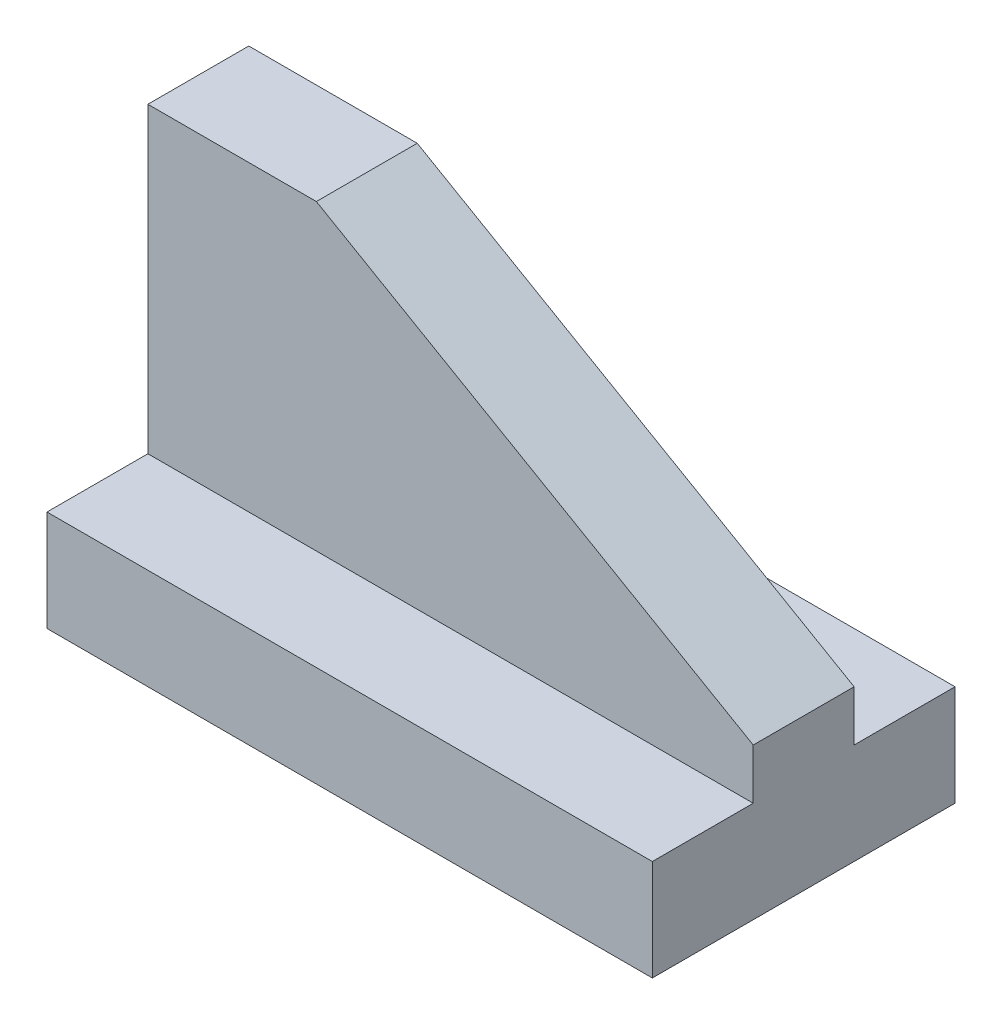
from build123d import *

# Parameters (mm, degrees)
SKETCH1_W           = 120
SKETCH1_H           = 20
BOSS_EXTRUDE1_DEPTH = 60
BOSS_EXTRUDE2_DEPTH = 20


with BuildPart() as part:
    # Sketch1 → Boss-Extrude1 (new body)
    with BuildSketch(Plane.XY):
        with Locations((60, 10)):
            Rectangle(SKETCH1_W, SKETCH1_H)
    extrude(amount=BOSS_EXTRUDE1_DEPTH)

    # Sketch2 → Boss-Extrude2 (add)
    with BuildSketch(Plane.XY.offset(20)):
        Polygon((0, 20), (0, 80), (33.397459622, 80), (120, 30), (120, 20), align=None)
    extrude(amount=BOSS_EXTRUDE2_DEPTH)


solid = part.part
